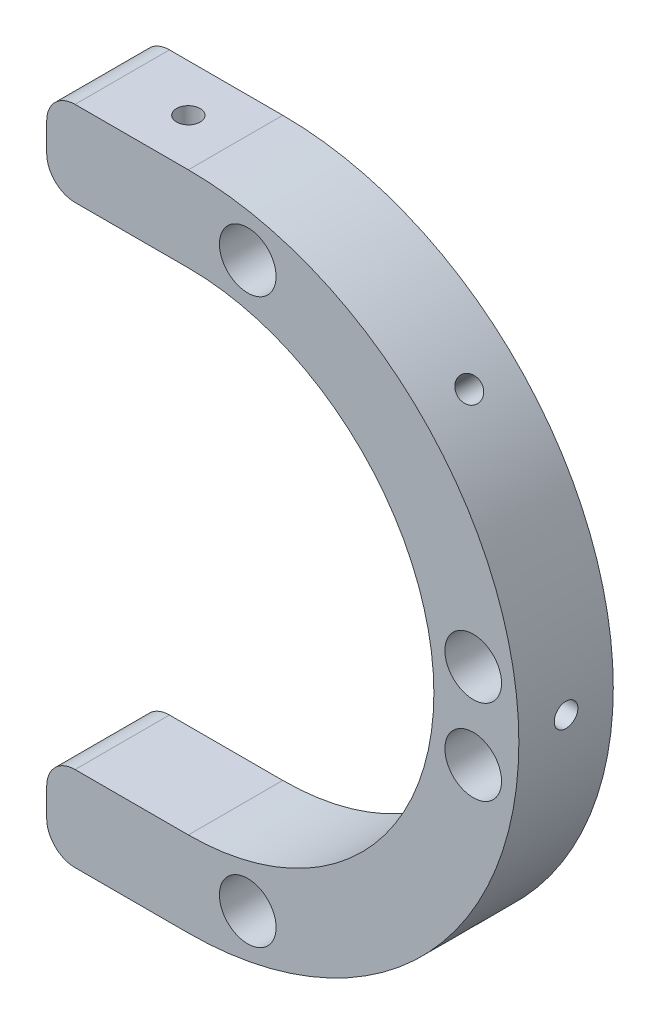
from build123d import *

# Parameters (mm, degrees)
SKETCH1_R                       = 3
BOSS_EXTRUDE1_DEPTH             = 10
FILLET1_R                       = 3
CIRPATTERN1_COUNT               = 2
CIRPATTERN1_ANGLE               = 45
CIRPATTERN2_COUNT               = 2
CIRPATTERN2_ANGLE               = 45
M3_TAPPED_HOLE4_D               = 2.5
M3_TAPPED_HOLE4_DEPTH           = 7.5
M3_TAPPED_HOLE4_TIP             = 0.751075774
M3_TAPPED_HOLE4_ON_FACE_2_D     = 2.5
M3_TAPPED_HOLE4_ON_FACE_2_DEPTH = 7.5
M3_TAPPED_HOLE4_ON_FACE_2_TIP   = 0.751075774


with BuildPart() as part:
    # Sketch1 → Boss-Extrude1 (new body)
    with BuildSketch(Plane.XY):
        with BuildLine():
            ThreePointArc((35, 0), (24.748737342, 24.748737342), (0, 35))
            ThreePointArc((0, 35), (-7.687744108, 34.145257219), (-15, 31.622776602))
            Line((-15, 31.622776602), (-15, 26))
            Line((-15, 26), (0, 26))
            ThreePointArc((0, 26), (3.168421474, 25.806222222), (6.289614512, 25.227777335))
            ThreePointArc((6.289614512, 25.227777335), (20.48816704, 16.00734242), (26, 0))
            ThreePointArc((26, 0), (20.48816704, -16.00734242), (6.289614512, -25.227777335))
            ThreePointArc((6.289614512, -25.227777335), (3.168421474, -25.806222222), (0, -26))
            Line((0, -26), (-15, -26))
            Line((-15, -26), (-15, -31.622776602))
            ThreePointArc((-15, -31.622776602), (-7.687744108, -34.145257219), (0, -35))
            ThreePointArc((0, -35), (24.748737342, -24.748737342), (35, 0))
        make_face()
        with Locations((6.289614512, -29.844442519)):
            Circle(SKETCH1_R, mode=Mode.SUBTRACT)
        with Locations((30.166206258, -4.5)):
            Circle(SKETCH1_R, mode=Mode.SUBTRACT)
        with Locations((30.166206258, 4.5)):
            Circle(SKETCH1_R, mode=Mode.SUBTRACT)
        with Locations((6.289614512, 29.844442519)):
            Circle(SKETCH1_R, mode=Mode.SUBTRACT)
        with BuildLine():
            ThreePointArc((-15, 31.622776602), (-7.687744108, 34.145257219), (0, 35))
            Line((0, 35), (-15, 35))
            Line((-15, 35), (-15, 31.622776602))
        make_face()
        with BuildLine():
            Line((-15, -35), (0, -35))
            ThreePointArc((0, -35), (-7.687744108, -34.145257219), (-15, -31.622776602))
            Line((-15, -31.622776602), (-15, -35))
        make_face()
    extrude(amount=BOSS_EXTRUDE1_DEPTH)

    # Fillet1
    fillet1_edges = [part.edges().sort_by_distance(p)[0] for p in [
        (-15, 26, 5),
        (-15, 35, 5),
        (-15, -35, 5),
        (-15, -26, 5),
    ]]
    fillet(fillet1_edges, radius=FILLET1_R)

    # Sketch14 → M3 Tapped Hole3 (revolve, cut)
    with BuildSketch(Plane(origin=(35, 0, 5), x_dir=(0, 0, -1), z_dir=(0, 1, 0))):
        Polygon((0, 0), (0, 8.251075774), (1.25, 7.5), (1.25, 0), align=None)
    m3_tapped_hole3 = revolve(axis=Axis((41.35, 0, 5), (-1, 0, 0)), mode=Mode.SUBTRACT)

    # CirPattern1: M3 Tapped Hole3 ×2 about axis
    cirpattern1_axis = Axis((0, 0, 0), (0, 0, 1))
    for i in range(1, CIRPATTERN1_COUNT):
        add(m3_tapped_hole3.rotate(cirpattern1_axis, i * CIRPATTERN1_ANGLE / (CIRPATTERN1_COUNT - 1)), mode=Mode.SUBTRACT)

    # CirPattern2: M3 Tapped Hole3 ×2 about axis
    cirpattern2_axis = Axis((0, 0, 10), (0, 0, -1))
    for i in range(1, CIRPATTERN2_COUNT):
        add(m3_tapped_hole3.rotate(cirpattern2_axis, i * CIRPATTERN2_ANGLE / (CIRPATTERN2_COUNT - 1)), mode=Mode.SUBTRACT)

    # M3 Tapped Hole4
    with Locations(Plane(origin=(-5, -35, 5), x_dir=(0, 0, -1), z_dir=(0, -1, 0))):
        with Locations((0, 0)):
            Hole(M3_TAPPED_HOLE4_D / 2, depth=M3_TAPPED_HOLE4_DEPTH)
            with Locations((0, 0, -(M3_TAPPED_HOLE4_DEPTH + M3_TAPPED_HOLE4_TIP / 2))):  # 118° drill point
                Cone(0, M3_TAPPED_HOLE4_D / 2, M3_TAPPED_HOLE4_TIP, mode=Mode.SUBTRACT)

    # M3 Tapped Hole4 on face 2
    with Locations(Plane(origin=(-5, 35, 5), x_dir=(0, 0, 1), z_dir=(0, 1, 0))):
        with Locations((0, 0)):
            Hole(M3_TAPPED_HOLE4_ON_FACE_2_D / 2, depth=M3_TAPPED_HOLE4_ON_FACE_2_DEPTH)
            with Locations((0, 0, -(M3_TAPPED_HOLE4_ON_FACE_2_DEPTH + M3_TAPPED_HOLE4_ON_FACE_2_TIP / 2))):  # 118° drill point
                Cone(0, M3_TAPPED_HOLE4_ON_FACE_2_D / 2, M3_TAPPED_HOLE4_ON_FACE_2_TIP, mode=Mode.SUBTRACT)


solid = part.part
